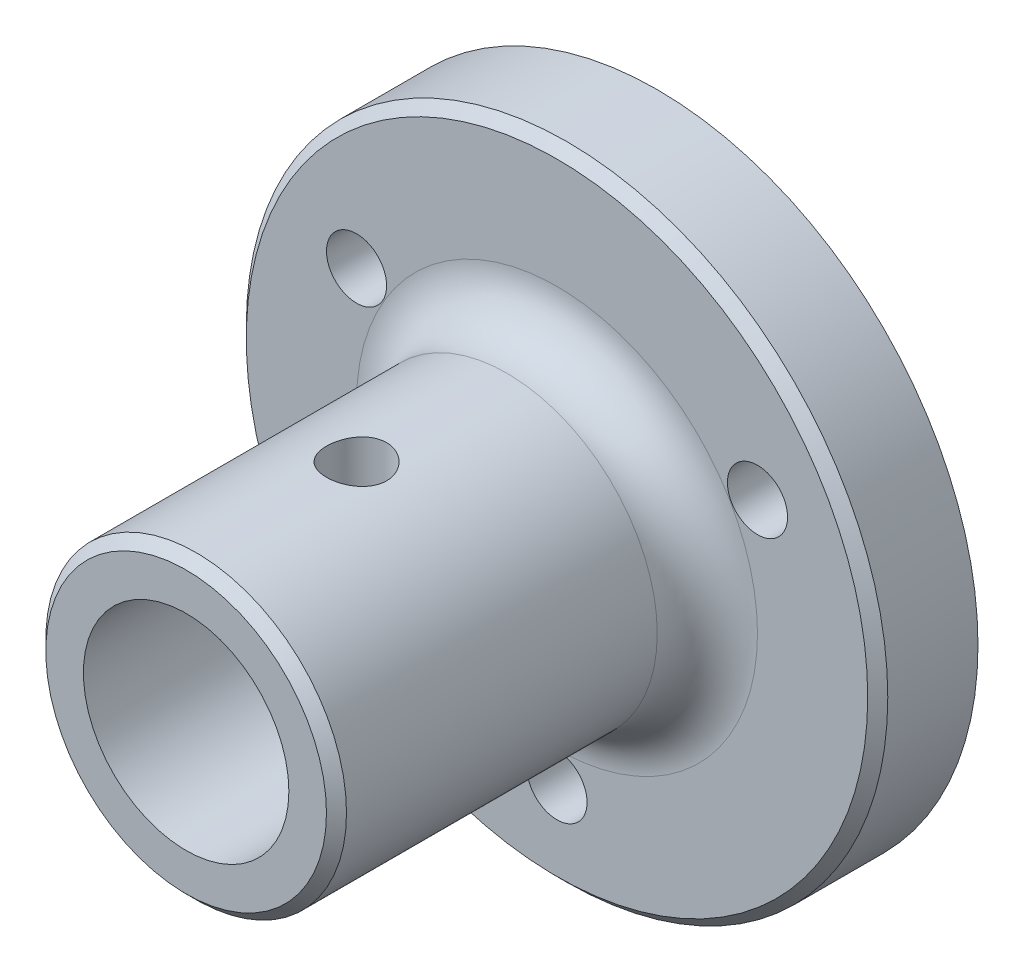
from build123d import *

# Parameters (mm, degrees)
SKETCH1_R               = 32
SKETCH1_R_2             = 3
BOSS_EXTRUDE1_DEPTH     = 10
SKETCH2_R               = 15
SKETCH2_R_2             = 10.25
BOSS_EXTRUDE2_DEPTH     = 37
SKETCH3_R               = 3
CUT_EXTRUDE1_DEPTH      = 33
CUT_EXTRUDE1_DEPTH_BACK = 33
FILLET_1_R              = 5
CHAMFER_1_SIZE          = 1


with BuildPart() as part:
    # Sketch1 → Boss-Extrude1 (new body)
    with BuildSketch(Plane.XY):
        Circle(SKETCH1_R)
        with Locations((20, 11.547005384)):
            Circle(SKETCH1_R_2, mode=Mode.SUBTRACT)
        with Locations((0, -23.094010768)):
            Circle(SKETCH1_R_2, mode=Mode.SUBTRACT)
        with Locations((-20, 11.547005384)):
            Circle(SKETCH1_R_2, mode=Mode.SUBTRACT)
    extrude(amount=BOSS_EXTRUDE1_DEPTH)

    # Sketch2 → Boss-Extrude2 (add)
    with BuildSketch(Plane.XY.offset(10)):
        Circle(SKETCH2_R)
        Circle(SKETCH2_R_2, mode=Mode.SUBTRACT)
    extrude(amount=BOSS_EXTRUDE2_DEPTH)

    # Sketch3 → Cut-Extrude1 (cut, two sides)
    with BuildSketch(Plane(origin=(0, 0, 0), x_dir=(1, 0, 0), z_dir=(0, 1, 0))) as cut_extrude1_sk:
        with Locations((0, -30)):
            Circle(SKETCH3_R)
    extrude(amount=CUT_EXTRUDE1_DEPTH, mode=Mode.SUBTRACT)
    extrude(cut_extrude1_sk.sketch, amount=-CUT_EXTRUDE1_DEPTH_BACK, mode=Mode.SUBTRACT)

    # 圆角1
    fillet_1_edges = [part.edges().sort_by_distance(p)[0] for p in [
        (-15, 0, 10),
    ]]
    fillet(fillet_1_edges, radius=FILLET_1_R)

    # 倒角1
    chamfer_1_edges = [part.edges().sort_by_distance(p)[0] for p in [
        (-15, 0, 47),
        (-32, 0, 10),
    ]]
    chamfer(chamfer_1_edges, length=CHAMFER_1_SIZE)


solid = part.part
